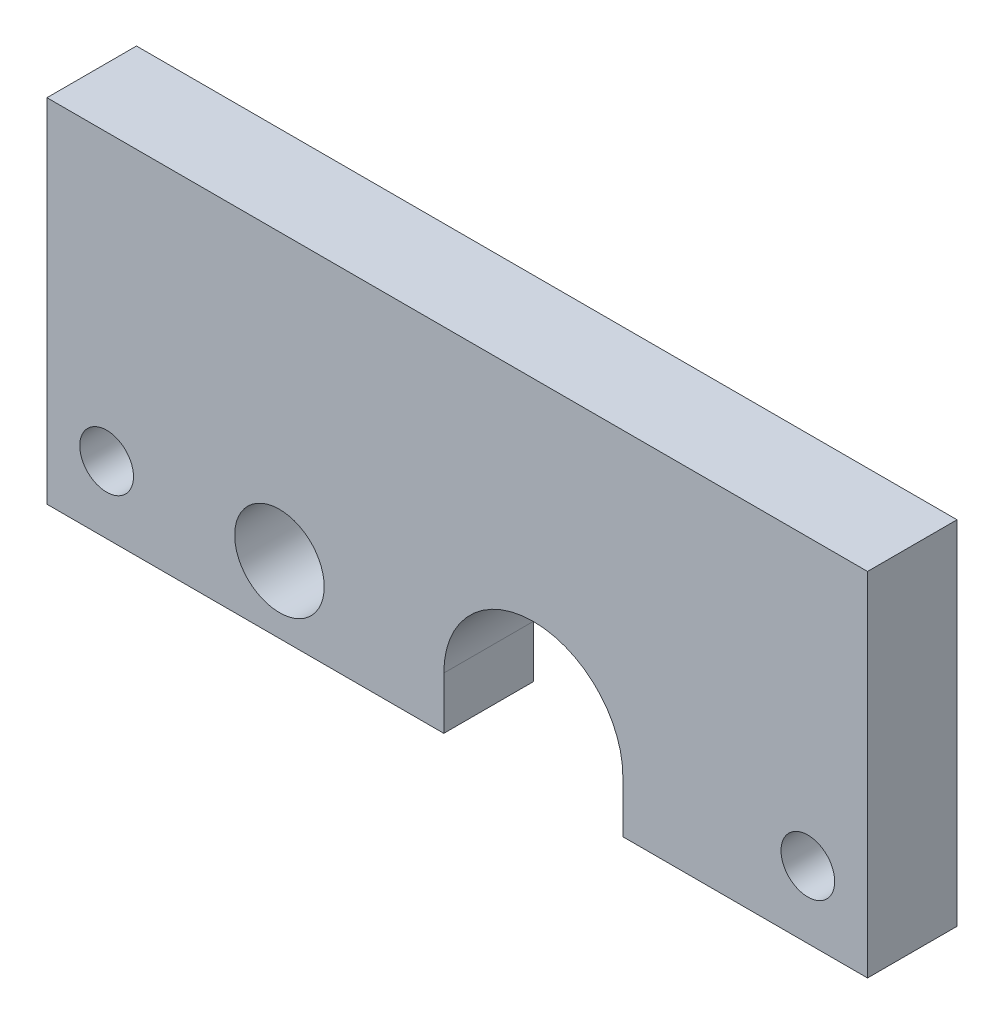
from build123d import *

# Parameters (mm, degrees)
MODEL_R                  = 1.8
MODEL_R_2                = 3
RESSALTO_EXTRUS_O1_DEPTH = 6


with BuildPart() as part:
    # Model → Ressalto-extrusão1 (new body)
    with BuildSketch(Plane.XY):
        with BuildLine():
            Line((27.28416807, 8.306820103), (27.28416807, 31.906820103))
            Line((27.28416807, 31.906820103), (82.28416807, 31.906820103))
            Line((82.28416807, 31.906820103), (82.28416807, 8.306820103))
            Line((82.28416807, 8.306820103), (65.88416807, 8.306820103))
            Line((65.88416807, 8.306820103), (65.88416807, 11.806820103))
            ThreePointArc((65.88416807, 11.806820103), (59.88416807, 17.806820103), (53.88416807, 11.806820103))
            Line((53.88416807, 11.806820103), (53.88416807, 8.306820103))
            Line((53.88416807, 8.306820103), (27.28416807, 8.306820103))
        make_face()
        with Locations((78.28416807, 12.806820103)):
            Circle(MODEL_R, mode=Mode.SUBTRACT)
        with Locations((42.86558438, 12.806820103)):
            Circle(MODEL_R_2, mode=Mode.SUBTRACT)
        with Locations((31.28416807, 12.806820103)):
            Circle(MODEL_R, mode=Mode.SUBTRACT)
    extrude(amount=RESSALTO_EXTRUS_O1_DEPTH)


solid = part.part
